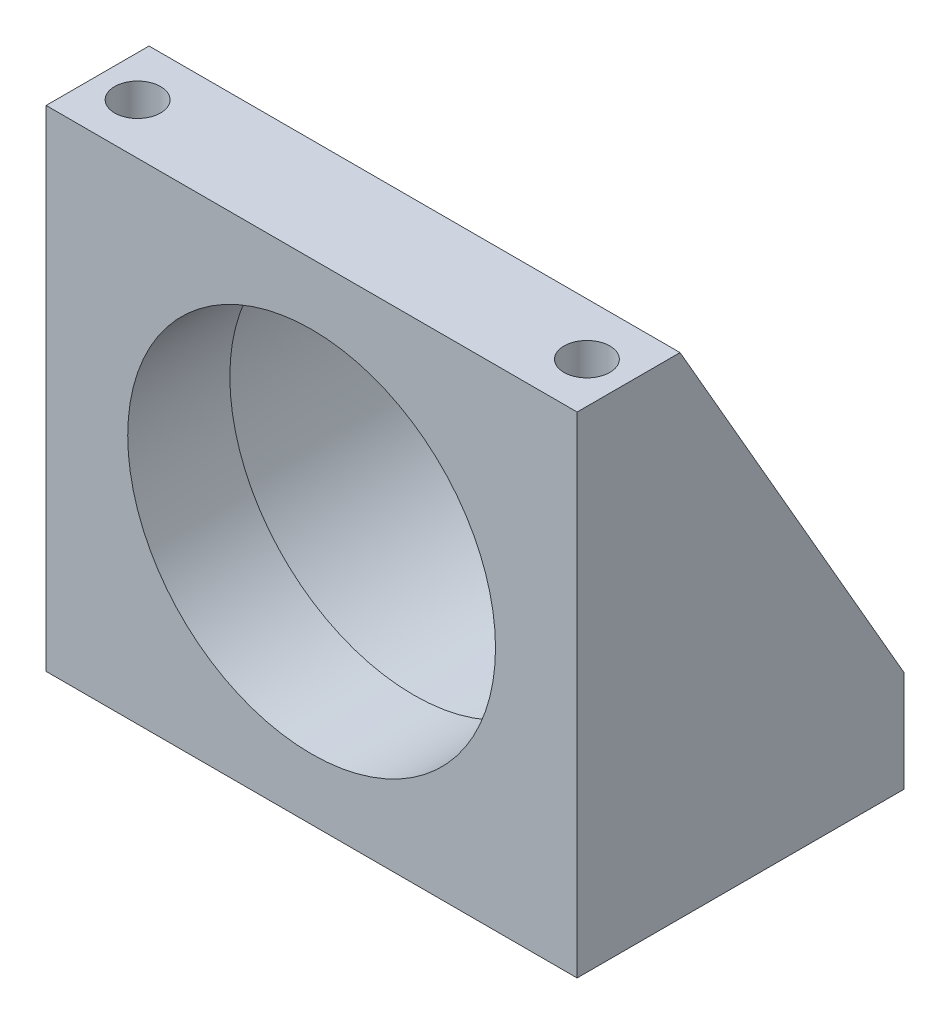
from build123d import *

# Parameters (mm, degrees)
SKETCH1_W          = 82.55
SKETCH1_H          = 76.2
SKETCH1_R          = 28.5877
EXTRUDE1_DEPTH     = 50.8
CUT_EXTRUDE1_DEPTH = 83.55
SKETCH3_R          = 30.988
CUT_EXTRUDE2_DEPTH = 34.925
FILLET1_R          = 1.524
HOLE1_D            = 7.1374
HOLE1_DEPTH        = 76.2


with BuildPart() as part:
    # Sketch1 → Extrude1 (new body)
    with BuildSketch(Plane.XY):
        with Locations((0, 38.1)):
            Rectangle(SKETCH1_W, SKETCH1_H)
        with Locations((0, 38.1)):
            Circle(SKETCH1_R, mode=Mode.SUBTRACT)
    extrude(amount=-EXTRUDE1_DEPTH)

    # Sketch2 → Cut-Extrude1 (cut, through all)
    with BuildSketch(Plane(origin=(41.275, 0, 0), x_dir=(0, 0, -1), z_dir=(1, 0, 0))):
        Polygon((16.002, 76.2), (50.8, 15.748), (50.8, 76.2), align=None)
    extrude(amount=-CUT_EXTRUDE1_DEPTH, mode=Mode.SUBTRACT)

    # Sketch3 → Cut-Extrude2 (cut)
    with BuildSketch(Plane(origin=(0, 0, -50.8), x_dir=(-1, 0, 0), z_dir=(0, 0, -1))):
        with Locations(Location((0, 38.1, 0), (0, 0, 313.83713531))):  # turned: the seam where the file's is
            Circle(SKETCH3_R)
    extrude(amount=-CUT_EXTRUDE2_DEPTH, mode=Mode.SUBTRACT)

    # Fillet1
    fillet1_edges = [part.edges().sort_by_distance(p)[0] for p in [
        (21.462624257, 60.452, -15.875),
    ]]
    fillet(fillet1_edges, radius=FILLET1_R)

    # Hole1
    with Locations(Plane(origin=(0, 76.2, 0), x_dir=(-1, 0, 0), z_dir=(0, 1, 0))):
        with Locations((34.925, -7.874), (-34.925, -7.874)):
            Hole(HOLE1_D / 2, depth=HOLE1_DEPTH)


solid = part.part
